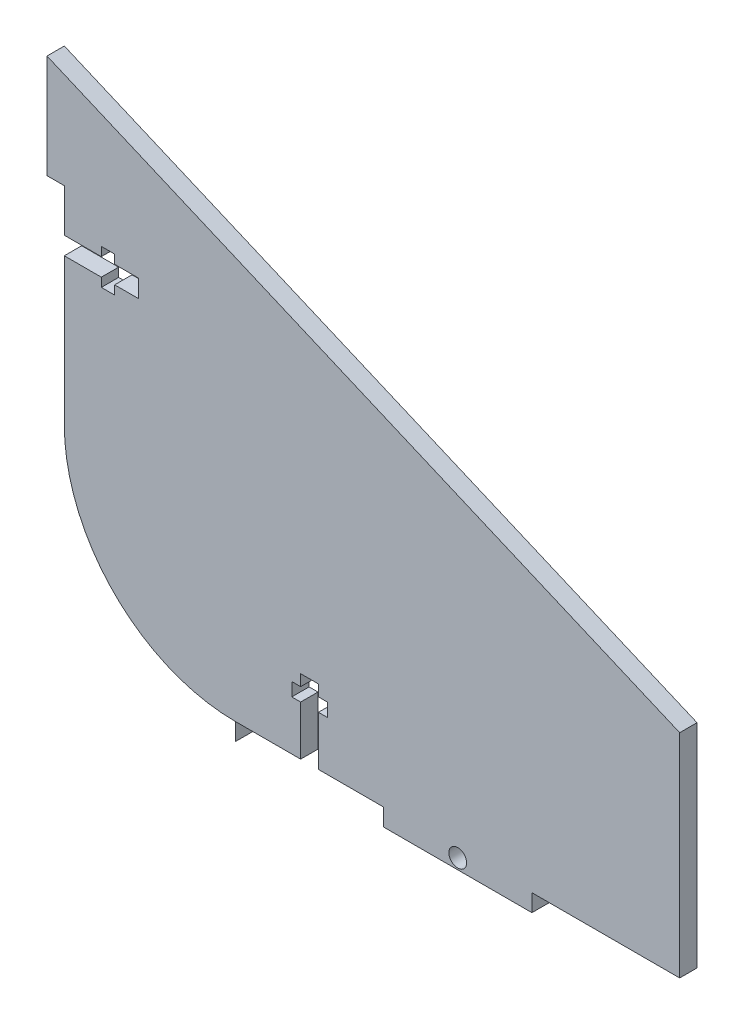
from build123d import *

# Parameters (mm, degrees)
BOSS_EXTRUDE1_DEPTH     = 2.9718
SKETCH3_W               = 2.9718
SKETCH3_H               = 17.78
CUT_EXTRUDE4_DEPTH      = 2.9718
CUT_EXTRUDE4_DEPTH_BACK = 3.9718
SKETCH4_R               = 1.524
CUT_EXTRUDE5_DEPTH      = 2.9718
CUT_EXTRUDE6_DEPTH      = 2.9718
CUT_EXTRUDE7_DEPTH      = 1
CUT_EXTRUDE7_DEPTH_BACK = 2.9718


with BuildPart() as part:
    # Sketch1 → Boss-Extrude1 (new body)
    with BuildSketch(Plane.XY):
        with BuildLine():
            Line((0, 0), (-76.2, 0))
            ThreePointArc((-76.2, 0), (-99.068034345, 9.472249971), (-108.540284316, 32.340284316))
            Line((-108.540284316, 32.340284316), (-108.540284316, 85.680284316))
            Line((-108.540284316, 85.680284316), (0, 39.416788246))
            Line((0, 39.416788246), (0, 0))
        make_face()
    extrude(amount=BOSS_EXTRUDE1_DEPTH)

    # Sketch3 → Cut-Extrude4 (cut, two sides)
    with BuildSketch(Plane.XY.offset(2.9718)) as cut_extrude4_sk:
        Polygon((-25.342092582, 2.9718), (-25.349200788, 0), (0, 0), (0, 2.9718), align=None)
        with BuildLine():
            Line((-76.2, 2.9718), (-76.202051529, 6.5e-08))
            ThreePointArc((-76.202051529, 6.5e-08), (-76.201025765, 1.6e-08), (-76.2, 0))
            Line((-76.2, 0), (-50.8, 0))
            Line((-50.8, 0), (-50.8, 2.9718))
            Line((-50.8, 2.9718), (-76.2, 2.9718))
        make_face()
        with Locations((-107.054384316, 59.010284316)):
            Rectangle(SKETCH3_W, SKETCH3_H)
    extrude(amount=CUT_EXTRUDE4_DEPTH, mode=Mode.SUBTRACT)
    extrude(cut_extrude4_sk.sketch, amount=-CUT_EXTRUDE4_DEPTH_BACK, mode=Mode.SUBTRACT)

    # Sketch4 → Cut-Extrude5 (cut)
    with BuildSketch(Plane.XY.offset(2.9718)):
        with Locations((-38.074600394, 1.794277041)):
            Circle(SKETCH4_R)
    extrude(amount=-CUT_EXTRUDE5_DEPTH, mode=Mode.SUBTRACT)

    # Sketch5 → Cut-Extrude6 (cut)
    with BuildSketch(Plane.XY.offset(2.9718)):
        Polygon((-105.568484316, 60.534284316), (-105.568484316, 59.010284316), (-92.868484316, 59.010284316), (-92.868484316, 60.534284316), (-96.932484316, 60.534284316), (-96.932484316, 62.058284316), (-99.218484316, 62.058284316), (-99.218484316, 60.534284316), align=None)
        Polygon((-92.868484316, 59.010284316), (-105.568484316, 59.010284316), (-105.568484316, 57.486284316), (-99.218484316, 57.486284316), (-99.218484316, 55.962284316), (-96.932484316, 55.962284316), (-96.932484316, 57.486284316), (-92.868484316, 57.486284316), align=None)
        Polygon((-65.024, 2.9718), (-63.5, 2.9718), (-63.5, 15.6718), (-65.024, 15.6718), (-65.024, 13.745923506), (-66.548, 13.745923506), (-66.548, 11.459923506), (-65.024, 11.459923506), align=None)
        Polygon((-63.5, 15.6718), (-63.5, 2.9718), (-61.976, 2.9718), (-61.976, 11.459923506), (-60.452, 11.459923506), (-60.452, 13.745923506), (-61.976, 13.745923506), (-61.976, 15.6718), align=None)
    extrude(amount=-CUT_EXTRUDE6_DEPTH, mode=Mode.SUBTRACT)

    # Sketch6 → Cut-Extrude7 (cut, two sides)
    with BuildSketch(Plane.XY.offset(2.9718)) as cut_extrude7_sk:
        with BuildLine():
            ThreePointArc((-105.568484316, 32.340284316), (-96.967313076, 11.574288587), (-76.201863011, 2.971800059))
            Line((-76.201863011, 2.971800059), (-76.202051529, 6.5e-08))
            ThreePointArc((-76.202051529, 6.5e-08), (-99.068759659, 9.472975307), (-108.540284316, 32.340284316))
            Line((-108.540284316, 32.340284316), (-108.540284316, 50.120284316))
            Line((-108.540284316, 50.120284316), (-105.568484316, 50.120284316))
            Line((-105.568484316, 50.120284316), (-105.568484316, 32.340284316))
        make_face()
    extrude(amount=CUT_EXTRUDE7_DEPTH, mode=Mode.SUBTRACT)
    extrude(cut_extrude7_sk.sketch, amount=-CUT_EXTRUDE7_DEPTH_BACK, mode=Mode.SUBTRACT)


solid = part.part
